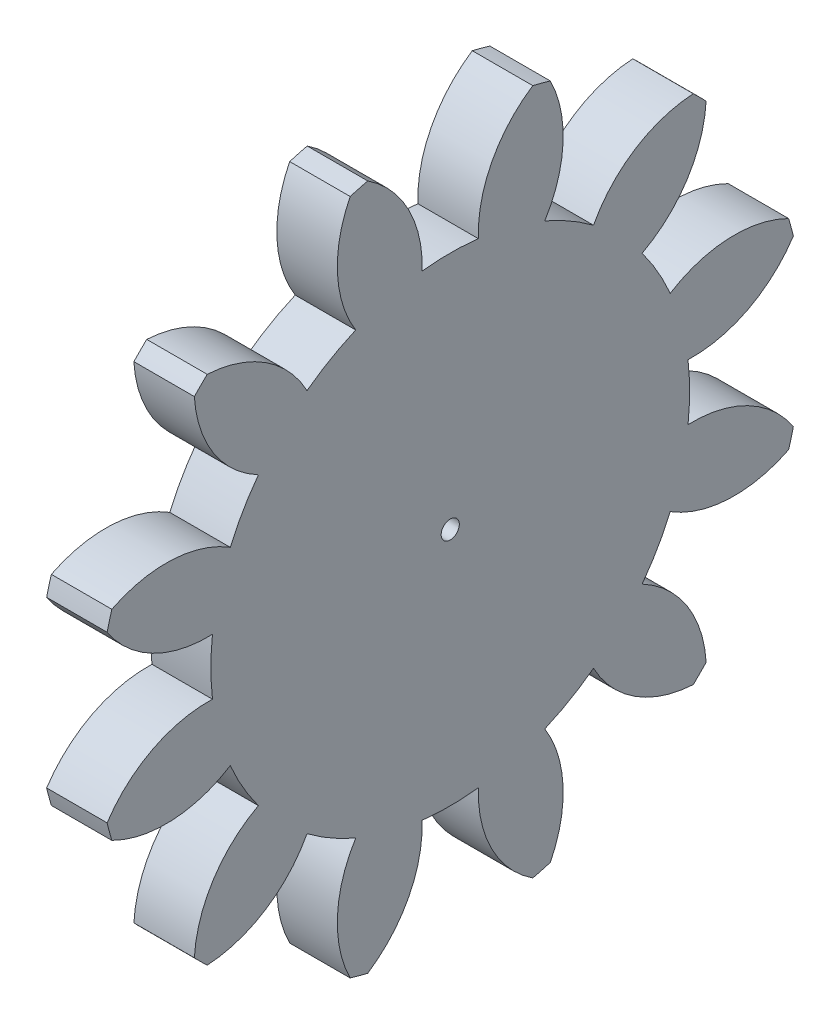
from build123d import *

# Parameters (mm, degrees)
BASPROSKE_W     = 3
BASPROSKE_H     = 17.5
TOOTHCUT_DEPTH  = 25.929901725
TEETHCUTS_COUNT = 12
TEETHCUTS_ANGLE = 330
BORSKE_R        = 0.45
BORE_DEPTH      = 50.0000508


with BuildPart() as part:
    # BasProSke → Base-Revolve (revolve)
    with BuildSketch(Plane(origin=(0, 0, 0), x_dir=(1, 0, 0), z_dir=(0, 1, 0)), mode=Mode.PRIVATE) as base_revolve_sk:
        with Locations((1.5, 8.75)):
            Rectangle(BASPROSKE_W, BASPROSKE_H)
    revolve(base_revolve_sk.sketch.rotate(Axis((-10, 0, 0), (1, 0, 0)), 180), axis=Axis((-10, 0, 0), (1, 0, 0)))

    # TooCutSke → ToothCut (cut, through all)
    with BuildSketch(Plane(origin=(0, 0, 0), x_dir=(0, 0, -1), z_dir=(1, 0, 0))):
        with BuildLine():
            ThreePointArc((1.394381134, 11.791843675), (0, 11.874), (-1.394381134, 11.791843675))
            ThreePointArc((-1.394381134, 11.791843675), (-2.068078374, 14.771857381), (-4.121860996, 17.033787221))
            ThreePointArc((-4.121860996, 17.033787221), (0, 17.5254), (4.121860996, 17.033787221))
            ThreePointArc((4.121860996, 17.033787221), (2.068078374, 14.771857381), (1.394381134, 11.791843675))
        make_face()
    toothcut = extrude(amount=TOOTHCUT_DEPTH, mode=Mode.SUBTRACT)

    # TeethCuts: ToothCut ×12 about axis
    teethcuts_axis = Axis((-10, 0, 0), (1, 0, 0))
    for i in range(1, TEETHCUTS_COUNT):
        add(toothcut.rotate(teethcuts_axis, i * TEETHCUTS_ANGLE / (TEETHCUTS_COUNT - 1)), mode=Mode.SUBTRACT)

    # BorSke → Bore (cut, symmetric)
    with BuildSketch(Plane(origin=(0, 0, 0), x_dir=(0, 0, -1), z_dir=(1, 0, 0))):
        with Locations(Location((0, 0, 0), (0, 0, 180))):
            Circle(BORSKE_R)
    extrude(amount=BORE_DEPTH, both=True, mode=Mode.SUBTRACT)


solid = part.part
